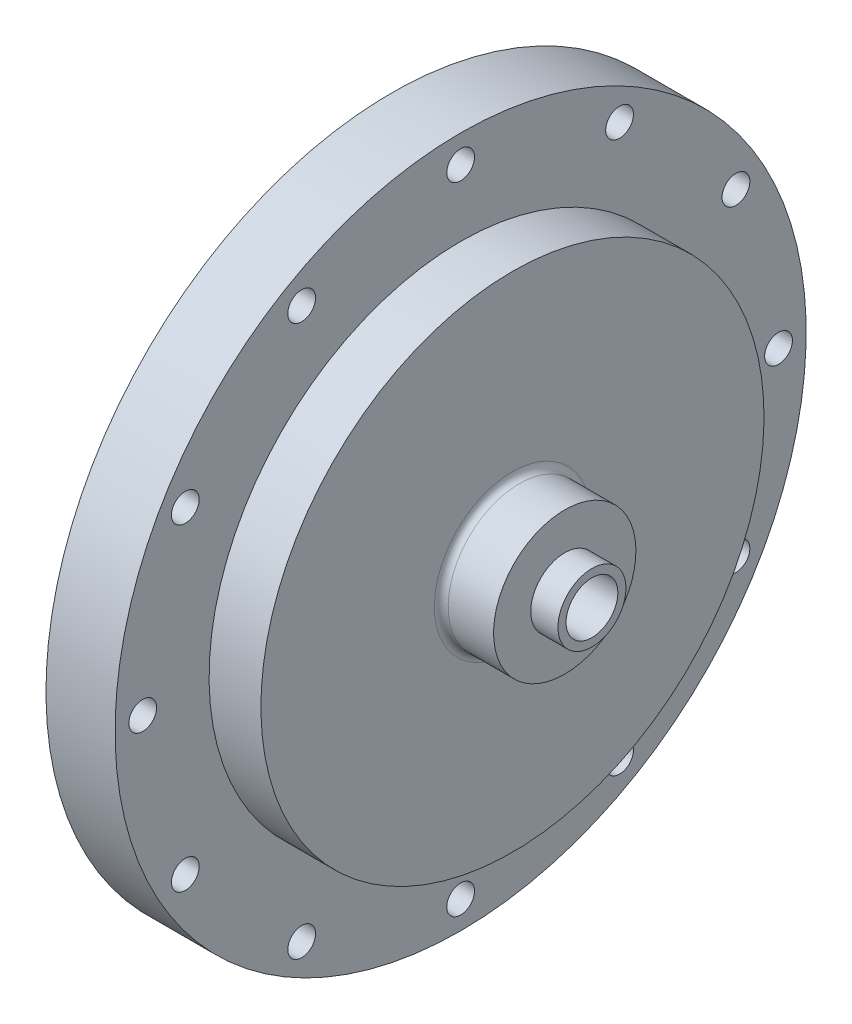
from build123d import *

# Parameters (mm, degrees)
SKETCH3_R                 = 4.7625
OXIDIZER_INLET_HOLE_DEPTH = 37.83
FLANGE_HOLES_D            = 5.1054
FLANGE_HOLES_DEPTH        = 22.225
DOWEL_HOLES_D             = 4.7625
DOWEL_HOLES_DEPTH         = 6.35
DOWEL_HOLES_TIP           = 1.430799349
SKETCH12_R                = 28.575
CUT_EXTRUDE2_DEPTH        = 9.525
SKETCH16_R                = 28.575
SKETCH17_R                = 4.7625
CIRPATTERN1_COUNT         = 8
FILLET1_R                 = 1.27
SKETCH25_OUTSIDE_W        = 165.668
SKETCH25_OUTSIDE_H        = 165.668
SKETCH25_OUTSIDE_R        = 46.228
CUT_EXTRUDE3_DEPTH        = 9.525


with BuildPart() as part:
    # Sketch2 → Main Structure (revolve)
    with BuildSketch(Plane.XY):
        Polygon((41.355, 13.081), (41.355, 6.2484), (46.355, 6.2484), (46.355, 0), (9.525, 0), (9.525, 63.5), (31.75, 63.5), (31.75, 13.081), align=None)
    revolve(axis=Axis((9.525, 0, 0), (1, 0, 0)))

    # Sketch3 → Oxidizer Inlet Hole (cut, through all)
    with BuildSketch(Plane(origin=(46.355, 0, 0), x_dir=(0, 0, -1), z_dir=(1, 0, 0))):
        Circle(SKETCH3_R)
    extrude(amount=-OXIDIZER_INLET_HOLE_DEPTH, mode=Mode.SUBTRACT)

    # Flange Holes
    with Locations(Plane(origin=(31.75, 0, 0), x_dir=(0, 0, 1), z_dir=(1, 0, 0))):
        with Locations((0, 58.42), (-29.21, 50.593204089), (-50.593204089, 29.21), (-58.42, 0), (-50.593204089, -29.21), (-29.21, -50.593204089), (0, -58.42), (29.21, -50.593204089), (50.593204089, -29.21), (58.42, 0), (50.593204089, 29.21), (29.21, 50.593204089)):
            Hole(FLANGE_HOLES_D / 2, depth=FLANGE_HOLES_DEPTH)

    # Dowel Holes
    with Locations(Plane.ZY.offset(-9.525)):
        with Locations((56.429386772, -15.120208615), (-56.429386772, 15.120208615)):
            Hole(DOWEL_HOLES_D / 2, depth=DOWEL_HOLES_DEPTH)
            with Locations((0, 0, -(DOWEL_HOLES_DEPTH + DOWEL_HOLES_TIP / 2))):  # 118° drill point
                Cone(0, DOWEL_HOLES_D / 2, DOWEL_HOLES_TIP, mode=Mode.SUBTRACT)

    # Sketch12 → Cut-Extrude2 (cut)
    with BuildSketch(Plane.ZY.offset(-9.525)):
        Circle(SKETCH12_R)
    extrude(amount=-CUT_EXTRUDE2_DEPTH, mode=Mode.SUBTRACT)

    # Sketch16 → Internal Flow Path Loft Cut section 0
    with BuildSketch(Plane.ZY.offset(-19.05)):
        Circle(SKETCH16_R)
    # Sketch17 → Internal Flow Path Loft Cut section 1
    with BuildSketch(Plane.ZY.offset(-30.48)):
        Circle(SKETCH17_R)
    loft(mode=Mode.SUBTRACT)

    # Sketch20 → #4-40 Tapped Hole1 (revolve, cut)
    with BuildSketch(Plane(origin=(9.525, 0, 33.3375), x_dir=(0, 0, 1), z_dir=(0, 1, 0))):
        Polygon((0, 0), (0, 13.887152758), (1.1303, 13.208), (1.1303, 0), align=None)
    f_4_40_tapped_hole1 = revolve(axis=Axis((3.175, 0, 33.3375), (1, 0, 0)), mode=Mode.SUBTRACT)

    # CirPattern1: #4-40 Tapped Hole1 ×8 about axis
    cirpattern1_axis = Axis((0, 0, 0), (1, 0, 0))
    for i in range(1, CIRPATTERN1_COUNT):
        add(f_4_40_tapped_hole1.rotate(cirpattern1_axis, i * 360 / CIRPATTERN1_COUNT), mode=Mode.SUBTRACT)

    # Fillet1
    fillet1_edges = [part.edges().sort_by_distance(p)[0] for p in [
        (31.75, -13.081, 0),
    ]]
    fillet(fillet1_edges, radius=FILLET1_R)

    # Sketch25 outside → Cut-Extrude3 (cut)
    with BuildSketch(Plane(origin=(31.75, 0, 0), x_dir=(0, 0, -1), z_dir=(1, 0, 0))):
        Rectangle(SKETCH25_OUTSIDE_W, SKETCH25_OUTSIDE_H)
        Circle(SKETCH25_OUTSIDE_R, mode=Mode.SUBTRACT)
    extrude(amount=-CUT_EXTRUDE3_DEPTH, mode=Mode.SUBTRACT)


solid = part.part
